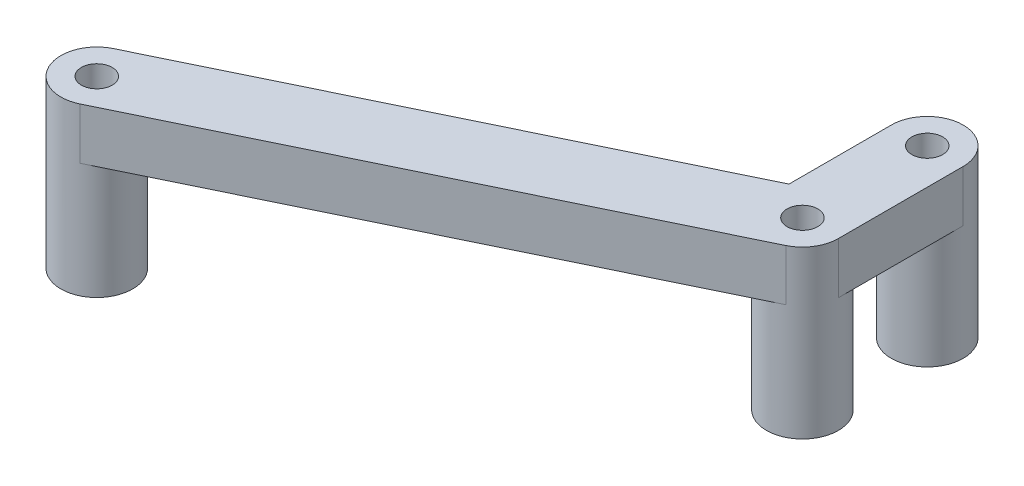
from build123d import *
from build123d.topology import SkipClean

# Parameters (mm, degrees)
SKETCH1_R           = 0.9525
BOSS_EXTRUDE1_DEPTH = 3.175
BOSS_EXTRUDE2_START = -3.175
SKETCH2_R           = 2.2225
SKETCH2_R_2         = 0.9525
BOSS_EXTRUDE2_DEPTH = 10.287


with BuildPart() as part:
    # Sketch1 → Boss-Extrude1 (new body)
    with BuildSketch(Plane(origin=(0, 0, 0), x_dir=(1, 0, 0), z_dir=(0, 1, 0))):
        with BuildLine():
            Line((17.1831, 11.4427), (17.1831, 3.7211))
            ThreePointArc((17.1831, 3.7211), (16.843824504, 2.540857771), (15.929582143, 1.720955041))
            Line((15.929582143, 1.720955041), (-13.483617857, -12.528444959))
            ThreePointArc((-13.483617857, -12.528444959), (-16.452744959, -11.497282143), (-15.421582143, -8.528155041))
            Line((-15.421582143, -8.528155041), (12.7381, 5.113970764))
            Line((12.7381, 5.113970764), (12.7381, 11.4427))
            ThreePointArc((12.7381, 11.4427), (14.9606, 13.6652), (17.1831, 11.4427))
        make_face()
        with Locations(Location((-14.4526, -10.5283, 0), (0, 0, 270))):
            Circle(SKETCH1_R, mode=Mode.SUBTRACT)
        with Locations(Location((14.9606, 11.4427, 0), (0, 0, 270))):
            Circle(SKETCH1_R, mode=Mode.SUBTRACT)
        with Locations(Location((14.9606, 3.7211, 0), (0, 0, 270))):
            Circle(SKETCH1_R, mode=Mode.SUBTRACT)
    extrude(amount=BOSS_EXTRUDE1_DEPTH)

    # Sketch2 → Boss-Extrude2 (add)
    with SkipClean():  # the faces are left unmerged after this step: merging them gives an invalid solid
        with BuildSketch(Plane.XZ.offset(BOSS_EXTRUDE2_START)):
            with Locations((14.9606, -11.4427)):
                Circle(SKETCH2_R)
            with Locations(Location((14.9606, -11.4427, 0), (0, 0, 90))):
                Circle(SKETCH2_R_2, mode=Mode.SUBTRACT)
            with Locations((14.9606, -3.7211)):
                Circle(SKETCH2_R)
            with Locations(Location((14.9606, -3.7211, 0), (0, 0, 90))):
                Circle(SKETCH2_R_2, mode=Mode.SUBTRACT)
            with Locations(Location((-14.4526, 10.5283, 0), (0, 0, 244.151855468))):
                Circle(SKETCH2_R)
            with Locations(Location((-14.4526, 10.5283, 0), (0, 0, 90))):
                Circle(SKETCH2_R_2, mode=Mode.SUBTRACT)
        extrude(amount=BOSS_EXTRUDE2_DEPTH)


solid = part.part
